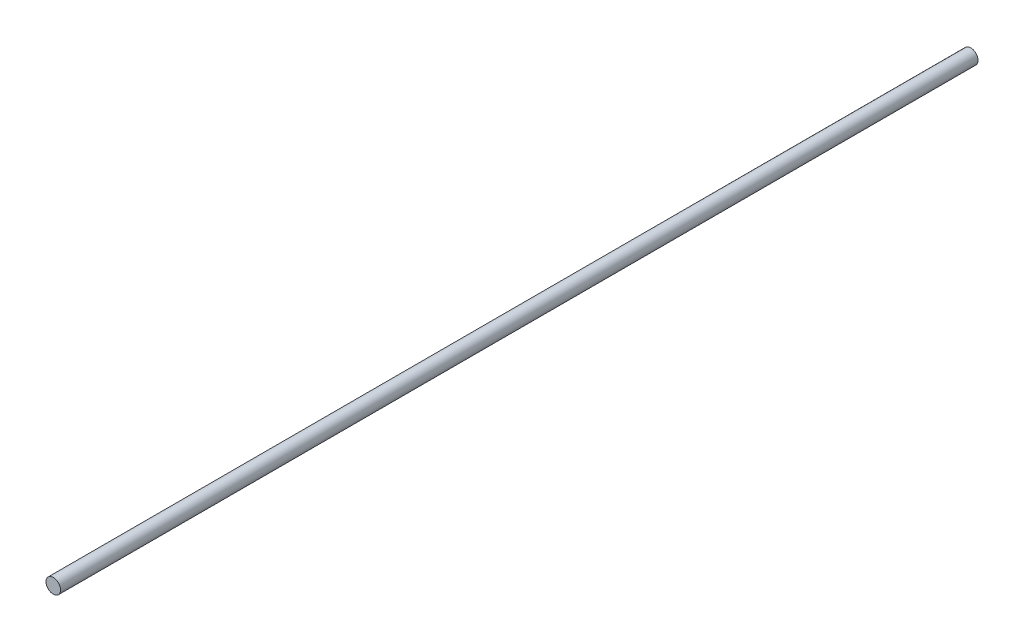
from build123d import *

# Parameters (mm, degrees)
SKETCH1_R           = 3.96875
BOSS_EXTRUDE1_DEPTH = 500


with BuildPart() as part:
    # Sketch1 → Boss-Extrude1 (new body)
    with BuildSketch(Plane.XY):
        Circle(SKETCH1_R)
    extrude(amount=BOSS_EXTRUDE1_DEPTH)


solid = part.part
